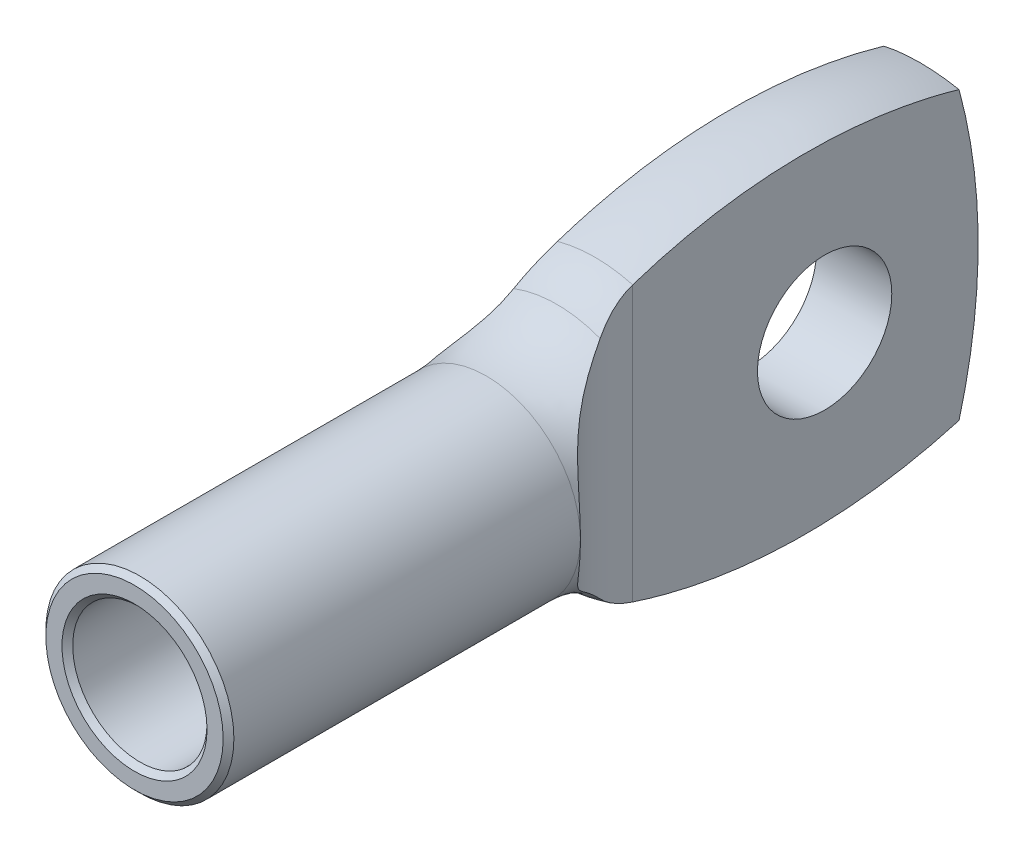
from build123d import *

# Parameters (mm, degrees)
SKETCH1_R           = 4.445
EXTRUDE1_DEPTH      = 38.1
SKETCH32_R          = 3.175
CUT_EXTRUDE9_DEPTH  = 39.615101321
SKETCH34_R          = 3.429
CUT_EXTRUDE11_DEPTH = 1.524
CUT_EXTRUDE11_DRAFT = -45
CHAMFER1_SIZE       = 0.254
SKETCH30_R          = 3.175
CUT_EXTRUDE7_DEPTH  = 12.7
CUT_EXTRUDE8_DEPTH  = 12.7


with BuildPart() as part:
    # Sketch1 → Extrude1 (new body)
    with BuildSketch(Plane.XY):
        Circle(SKETCH1_R)
    extrude(amount=-EXTRUDE1_DEPTH)

    # Sketch32 → Cut-Extrude9 (cut, through all)
    with BuildSketch(Plane.XY):
        Circle(SKETCH32_R)
    extrude(amount=-CUT_EXTRUDE9_DEPTH, mode=Mode.SUBTRACT)


with BuildPart() as cut_extrude11_tool:
    # Sketch34 → Cut-Extrude11 (with draft: the straight prism first)
    with BuildSketch(Plane.XY):
        Circle(SKETCH34_R)
    extrude(amount=-CUT_EXTRUDE11_DEPTH)
    # Cut-Extrude11: the draft: its side faces are tilted about the plane it starts from
    cut_extrude11_sides = [cut_extrude11_tool.faces().sort_by_distance(p)[0] for p in [
        (-3.429, 0, -0.762),
    ]]
    draft(cut_extrude11_sides, Plane.XY, CUT_EXTRUDE11_DRAFT)


with BuildPart() as part_1:
    add(part.part)

    # Cut-Extrude11: cut by cut_extrude11_tool
    add(cut_extrude11_tool.part, mode=Mode.SUBTRACT)

    # Chamfer1
    chamfer1_edges = [part_1.edges().sort_by_distance(p)[0] for p in [
        (-4.445, 0, 0),
    ]]
    chamfer(chamfer1_edges, length=CHAMFER1_SIZE)

    # Sketch29 → Revolve2 (revolve)
    with BuildSketch(Plane(origin=(0, 0, 0), x_dir=(0, 0, -1), z_dir=(1, 0, 0))):
        with BuildLine():
            Line((16.328571429, 0), (16.328571429, 2.350110803))
            Line((16.328571429, 2.350110803), (16.328571429, 4.445))
            Line((16.328571429, 4.445), (16.630196429, 4.445))
            ThreePointArc((16.630196429, 4.445), (18.413645234, 4.771067643), (19.966347576, 5.707083234))
            ThreePointArc((19.966347576, 5.707083234), (20.815620725, 6.31294757), (21.771428571, 6.731))
            ThreePointArc((21.771428571, 6.731), (29.935714286, 8.001), (38.1, 6.731))
            Line((38.1, 6.731), (38.1, 0))
            Line((38.1, 0), (16.328571429, 0))
        make_face()
    revolve(axis=Axis((0, 0, 0), (0, 0, -1)))

    # Sketch30 → Cut-Extrude7 (cut, symmetric)
    with BuildSketch(Plane(origin=(0, 0, 0), x_dir=(0, 0, -1), z_dir=(1, 0, 0))):
        with Locations((30.842857143, 0)):
            Circle(SKETCH30_R)
        with BuildLine():
            Line((44.45, 8.001), (36.83, 8.001))
            ThreePointArc((36.83, 8.001), (38.1, 0), (36.83, -8.001))
            Line((36.83, -8.001), (44.45, -8.001))
            Line((44.45, -8.001), (44.45, 8.001))
        make_face()
    extrude(amount=CUT_EXTRUDE7_DEPTH, both=True, mode=Mode.SUBTRACT)

    # Sketch31 → Cut-Extrude8 (cut, symmetric)
    with BuildSketch(Plane(origin=(0, 0, 0), x_dir=(1, 0, 0), z_dir=(0, 1, 0))):
        with BuildLine():
            Line((1.778, 38.1), (1.778, 21.771428571))
            ThreePointArc((1.778, 21.771428571), (2.484425862, 18.87551952), (4.445, 16.630196429))
            Line((4.445, 16.630196429), (14.478, 16.630196429))
            Line((14.478, 16.630196429), (14.478, 38.1))
            Line((14.478, 38.1), (1.778, 38.1))
        make_face()
        with BuildLine():
            Line((-1.778, 38.1), (-1.778, 21.771428571))
            ThreePointArc((-1.778, 21.771428571), (-2.484425862, 18.87551952), (-4.445, 16.630196429))
            Line((-4.445, 16.630196429), (-14.478, 16.630196429))
            Line((-14.478, 16.630196429), (-14.478, 38.1))
            Line((-14.478, 38.1), (-1.778, 38.1))
        make_face()
    extrude(amount=CUT_EXTRUDE8_DEPTH, both=True, mode=Mode.SUBTRACT)


solid = part_1.part
